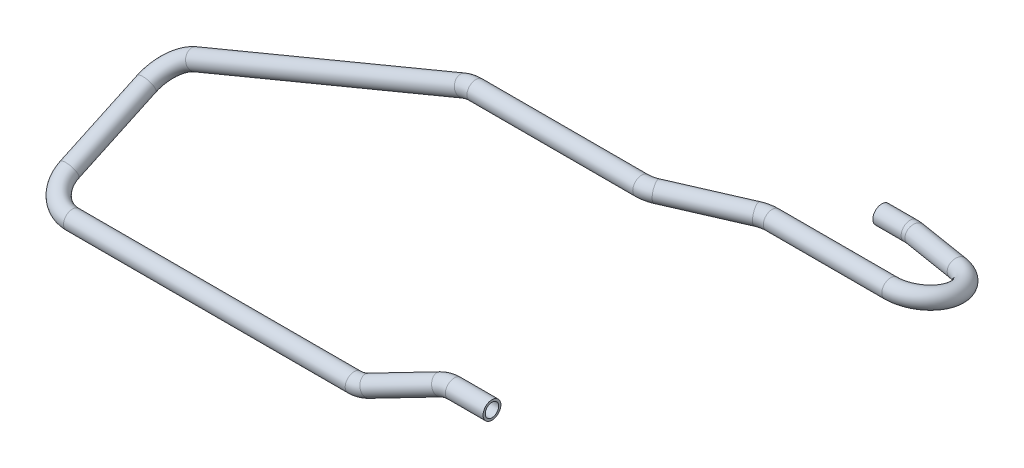
from build123d import *

# Parameters (mm, degrees)
SKETCH1_R   = 6
SKETCH1_R_2 = 4.5


with BuildPart() as part:
    # Sweep1: sweep along a curve in space
    with BuildLine() as sweep1_path:
        Line((0, 0, 0), (-25.327407146, 0, 0))
        ThreePointArc((-25.327407146, 0, 0), (-29.888459095, -0.471116072, 0.171314935), (-34.231754488, -1.861971975, 0.677080718))
        Line((-34.231754488, -1.861971975, 0.677080718), (-75.768245512, -20.138028025, 7.322919282))
        ThreePointArc((-75.768245512, -20.138028025, 7.322919282), (-80.111540905, -21.528883928, 7.828685065), (-84.672592854, -22, 8))
        Line((-84.672592854, -22, 8), (-274, -22, 8))
        ThreePointArc((-274, -22, 8), (-288.849242405, -19.400577517, 2.425520495), (-295, -13.125016503, -11.032463528))
        Line((-295, 11.032110394, -62.837589339), (-295, -13.125016503, -11.032463528))
        ThreePointArc((-295, 11.032110394, -62.837589339), (-290.326763001, 18.370157237, -74.414240676), (-278.529276145, 25.405428874, -79))
        Line((-278.529276145, 25.405428874, -79), (-97.865461107, 100.395305511, -79))
        ThreePointArc((-97.865461107, 100.395305511, -79), (-93.919280038, 101.594755422, -79), (-89.814772717, 101.99977983, -79))
        Line((-89.814772717, 101.99977983, -79), (21.61770884, 101.99977983, -79))
        ThreePointArc((21.61770884, 101.99977983, -79), (25.90758845, 101.99977983, -79.44283743), (30.016542416, 101.99977983, -80.752673054))
        Line((30.016542416, 101.99977983, -80.752673054), (76.983457584, 101.99977983, -101.247326946))
        ThreePointArc((85.38229116, 101.99977983, -103), (81.09241155, 101.99977983, -102.55716257), (76.983457584, 101.99977983, -101.247326946))
        Line((85.38229116, 101.99977983, -103), (165, 101.99977983, -103))
        ThreePointArc((165, 101.99977983, -103), (185.907102089, 98.871775015, -121.768028888), (168.928722286, 95.155976533, -144.062819784))
        Line((133.946865608, 94.060733999, -150.634274983), (168.928722286, 95.155976533, -144.062819784))
        ThreePointArc((133.946865608, 94.060733999, -150.634274983), (131.991232841, 94.015052153, -150.908366065), (130.018143322, 93.99977983, -151))
        Line((130.018143322, 93.99977983, -151), (111, 93.99977983, -151))
    # Sketch1 → Sweep1 (sweep)
    with BuildSketch(Plane.ZY):
        Circle(SKETCH1_R)
        Circle(SKETCH1_R_2, mode=Mode.SUBTRACT)
    sweep(path=sweep1_path.line)


solid = part.part
